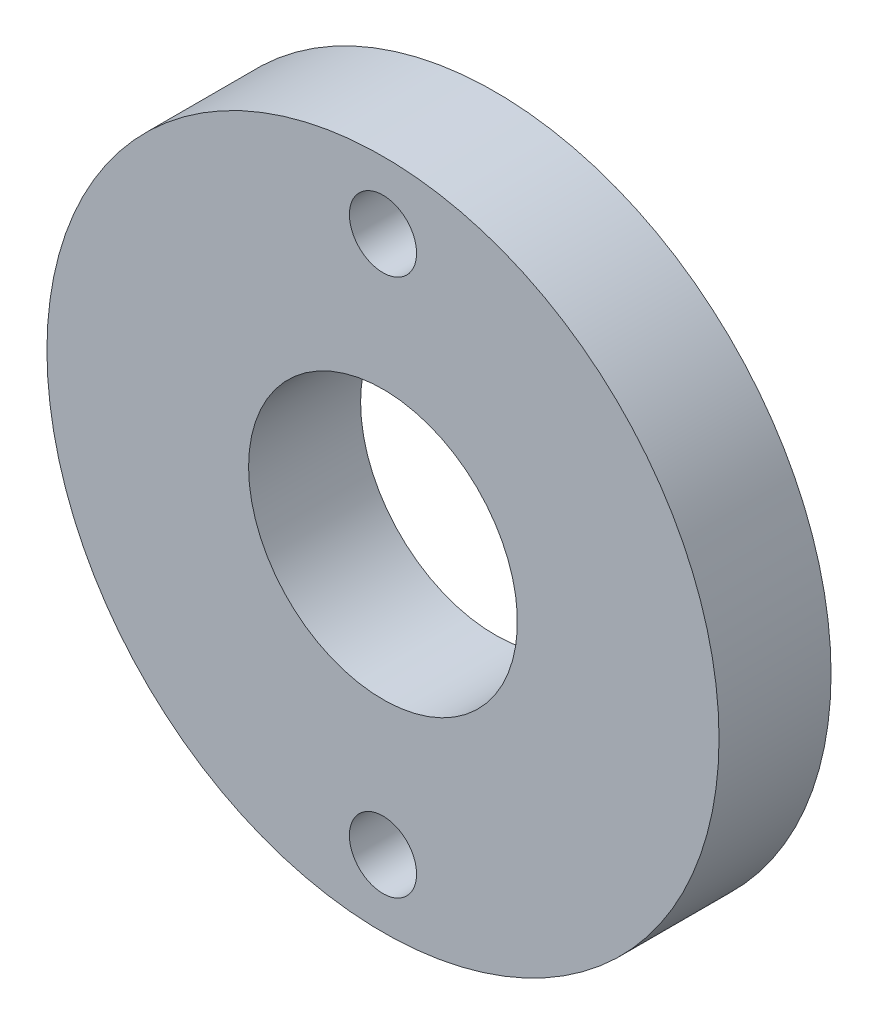
from build123d import *

# Parameters (mm, degrees)
SKETCH19_R          = 15
SKETCH19_R_2        = 6
SKETCH19_R_3        = 1.5
BOSS_EXTRUDE1_DEPTH = 5


with BuildPart() as part:
    # Sketch19 → Boss-Extrude1 (new body)
    with BuildSketch(Plane(origin=(259.301545348, 0, 0), x_dir=(-1, 0, 0), z_dir=(0, 0, -1))):
        with Locations((0, -148.573704322)):
            Circle(SKETCH19_R)
        with Locations((0, -148.573704322)):
            Circle(SKETCH19_R_2, mode=Mode.SUBTRACT)
        with Locations((0, -136.573704322)):
            Circle(SKETCH19_R_3, mode=Mode.SUBTRACT)
        with Locations((0, -160.573704322)):
            Circle(SKETCH19_R_3, mode=Mode.SUBTRACT)
    extrude(amount=BOSS_EXTRUDE1_DEPTH)


solid = part.part
